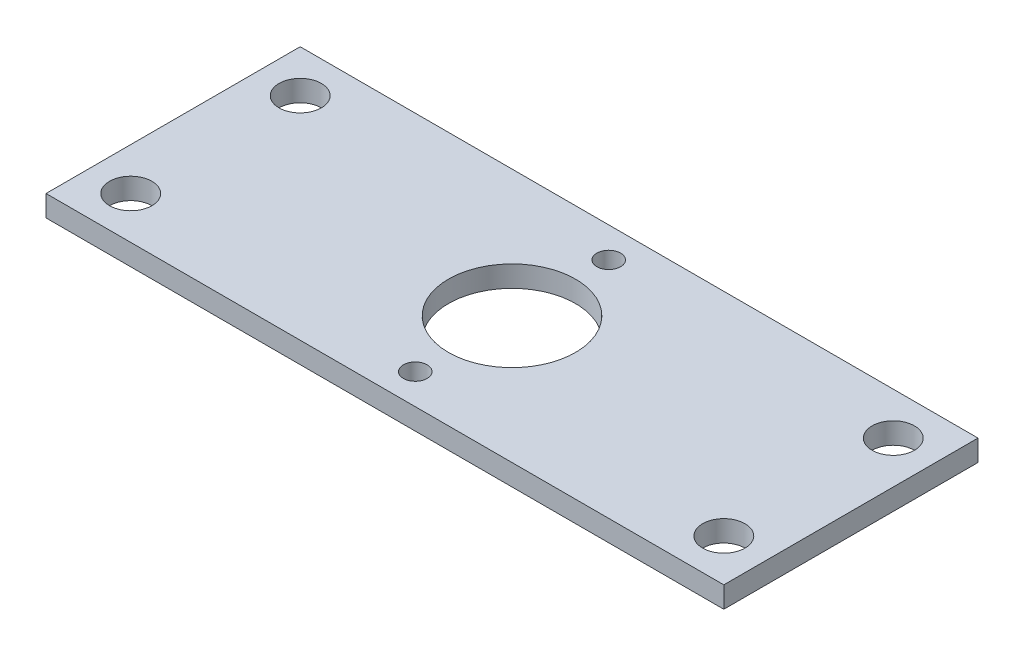
from build123d import *

# Parameters (mm, degrees)
SKETCH1_W           = 25.4
SKETCH1_H           = 38.1
BOSS_EXTRUDE1_DEPTH = 3.175
SKETCH2_R           = 9.525
SKETCH2_R_2         = 1.778
CUT_EXTRUDE1_DEPTH  = 3.175
SKETCH3_W           = 38.1
SKETCH3_H           = 3.175
BOSS_EXTRUDE2_DEPTH = 38.1
SKETCH6_W           = 38.1
SKETCH6_H           = 3.175
BOSS_EXTRUDE4_DEPTH = 38.1
SKETCH4_R           = 3.175
CUT_EXTRUDE2_DEPTH  = 4.175


with BuildPart() as part:
    # Sketch1 → Boss-Extrude1 (new body)
    with BuildSketch(Plane(origin=(0, 0, 0), x_dir=(1, 0, 0), z_dir=(0, 1, 0))):
        Rectangle(SKETCH1_W, SKETCH1_H)
    extrude(amount=BOSS_EXTRUDE1_DEPTH)

    # Sketch2 → Cut-Extrude1 (cut)
    with BuildSketch(Plane(origin=(0, 3.175, 0), x_dir=(1, 0, 0), z_dir=(0, 1, 0))):
        Circle(SKETCH2_R)
        with Locations((0, -14.5)):
            Circle(SKETCH2_R_2)
        with Locations((0, 14.5)):
            Circle(SKETCH2_R_2)
    extrude(amount=-CUT_EXTRUDE1_DEPTH, mode=Mode.SUBTRACT)

    # Sketch3 → Boss-Extrude2 (add)
    with BuildSketch(Plane.ZY.offset(12.7)):
        with Locations((0, 1.5875)):
            Rectangle(SKETCH3_W, SKETCH3_H)
    extrude(amount=BOSS_EXTRUDE2_DEPTH)

    # Sketch6 → Boss-Extrude4 (add)
    with BuildSketch(Plane(origin=(12.7, 0, 0), x_dir=(0, 0, -1), z_dir=(1, 0, 0))):
        with Locations((0, 1.5875)):
            Rectangle(SKETCH6_W, SKETCH6_H)
    extrude(amount=BOSS_EXTRUDE4_DEPTH)

    # Sketch4 → Cut-Extrude2 (cut, through all)
    with BuildSketch(Plane(origin=(0, 3.175, 0), x_dir=(1, 0, 0), z_dir=(0, 1, 0))):
        with Locations((-44.45, 12.7)):
            Circle(SKETCH4_R)
        with Locations((-44.45, -12.7)):
            Circle(SKETCH4_R)
        with Locations((44.45, -12.7)):
            Circle(SKETCH4_R)
        with Locations((44.45, 12.7)):
            Circle(SKETCH4_R)
    extrude(amount=-CUT_EXTRUDE2_DEPTH, mode=Mode.SUBTRACT)


solid = part.part
